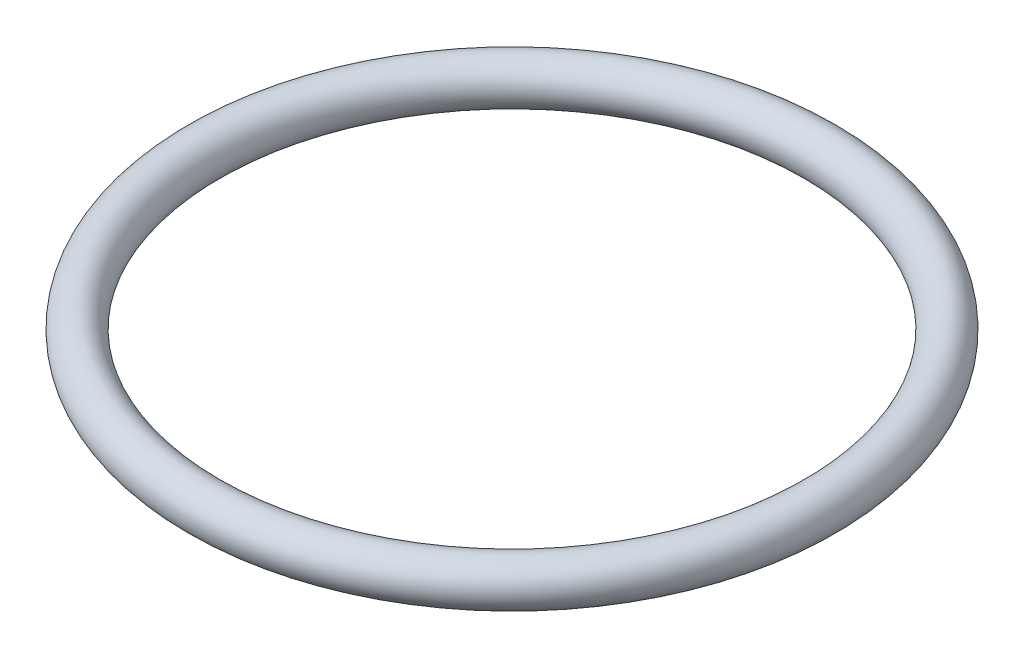
from build123d import *

# Parameters (mm, degrees)
SKETCH1_R = 1.5


with BuildPart() as part:
    # Sketch1 → Revolve1 (revolve)
    with BuildSketch(Plane.XY):
        with Locations((-21, 0)):
            Circle(SKETCH1_R)
    revolve(axis=Axis((0, 3.168228301, 0), (0, -1, 0)))


solid = part.part
